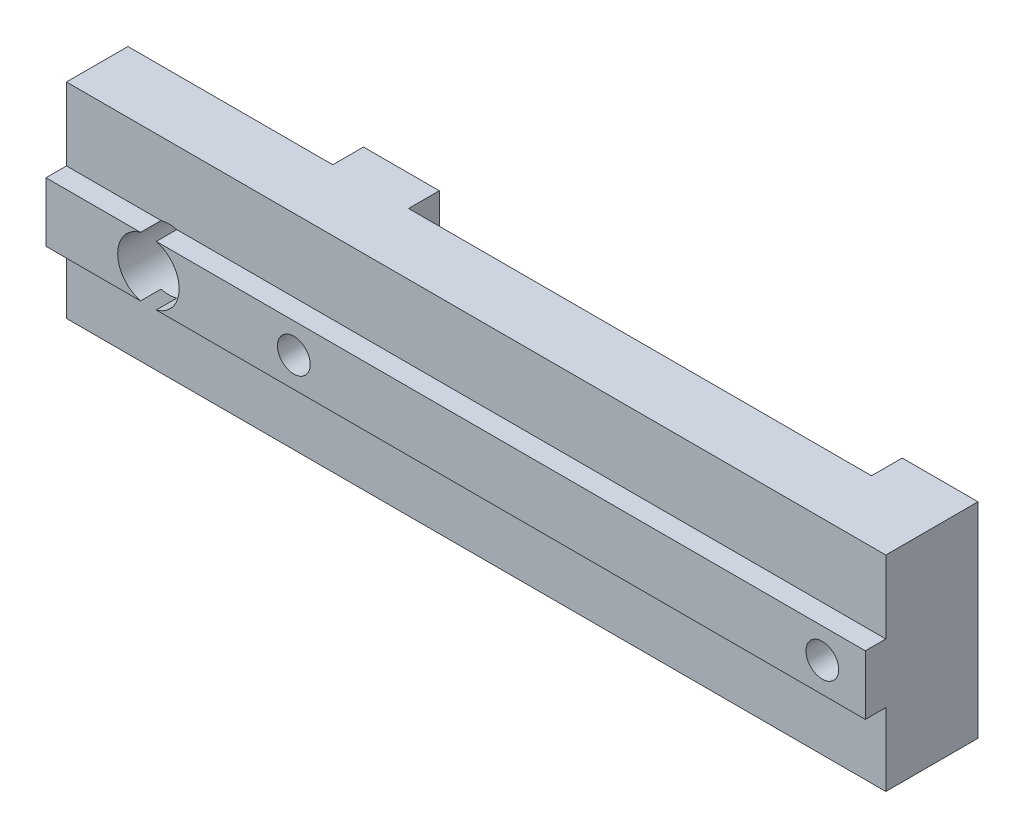
from build123d import *

# Parameters (mm, degrees)
ESQUISSE1_W        = 40
ESQUISSE1_H        = 10
MAIN_DEPTH         = 3
ESQUISSE2_W        = 40
ESQUISSE2_H        = 2.9
CENTRALFIX_DEPTH   = 1
ESQUISSE3_R        = 1.5
HOLESFIX_DEPTH     = 5
SKETCH1_W          = 3.7
SKETCH1_H          = 10
FIXSUPPORT_DEPTH   = 1.5
SKETCH2_R          = 0.8
CUT_EXTRUDE1_DEPTH = 6.5


with BuildPart() as part:
    # Esquisse1 → Main (new body)
    with BuildSketch(Plane.XY):
        with Locations((20, 5)):
            Rectangle(ESQUISSE1_W, ESQUISSE1_H)
    extrude(amount=MAIN_DEPTH)

    # Esquisse2 → CentralFix (add)
    with BuildSketch(Plane.XY.offset(3)):
        with Locations((20, 5)):
            Rectangle(ESQUISSE2_W, ESQUISSE2_H)
    extrude(amount=CENTRALFIX_DEPTH)

    # Esquisse3 → HolesFix (cut, through all)
    with BuildSketch(Plane(origin=(0, 0, 0), x_dir=(-1, 0, 0), z_dir=(0, 0, -1))):
        with Locations((-5, 5)):
            Circle(ESQUISSE3_R)
    extrude(amount=-HOLESFIX_DEPTH, mode=Mode.SUBTRACT)

    # Sketch1 → FixSupport (add)
    with BuildSketch(Plane(origin=(0, 0, 0), x_dir=(-1, 0, 0), z_dir=(0, 0, -1))):
        with Locations((-11.85, 5)):
            Rectangle(SKETCH1_W, SKETCH1_H)
        with Locations((-38.15, 5)):
            Rectangle(SKETCH1_W, SKETCH1_H)
    extrude(amount=FIXSUPPORT_DEPTH)

    # Sketch2 → Cut-Extrude1 (cut, through all)
    with BuildSketch(Plane(origin=(0, 0, -1.5), x_dir=(-1, 0, 0), z_dir=(0, 0, -1))):
        with Locations((-37.9, 5)):
            Circle(SKETCH2_R)
        with Locations((-12.1, 5)):
            Circle(SKETCH2_R)
    extrude(amount=-CUT_EXTRUDE1_DEPTH, mode=Mode.SUBTRACT)


solid = part.part
